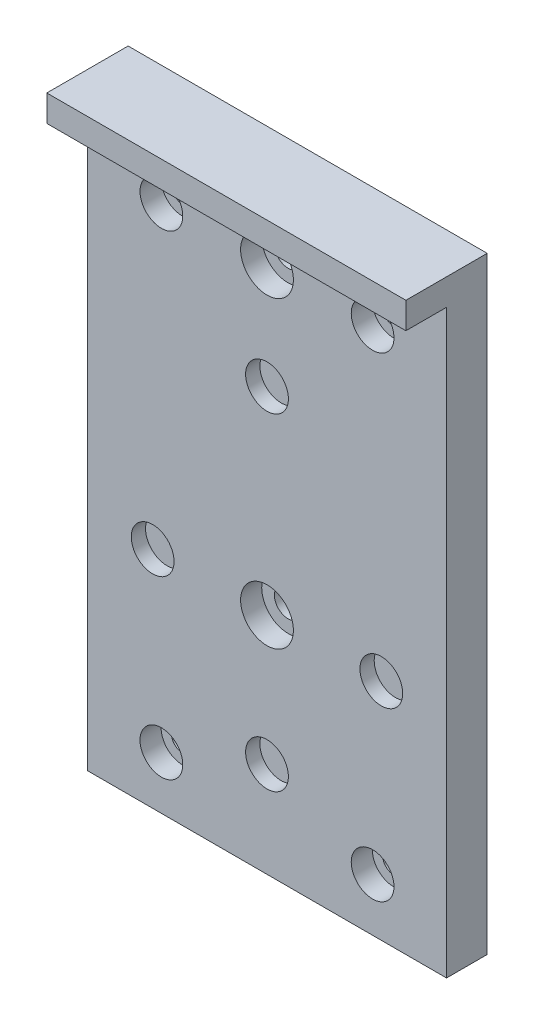
from build123d import *

# Parameters (mm, degrees)
SKETCH1_W                = 68
SKETCH1_H                = 110
SKETCH1_R                = 2.1
SKETCH1_R_2              = 4.05
SKETCH1_R_3              = 2.6
BOSS_EXTRUDE1_DEPTH      = 7.7
SKETCH2_R                = 6.304633146
SKETCH2_R_2              = 7.334333348
SKETCH2_R_3              = 8.114040952
SKETCH2_R_4              = 11.073656437
BOSS_EXTRUDE2_DEPTH      = 5
SKETCH3_R                = 4.05
SKETCH3_R_2              = 5
CUT_EXTRUDE1_DEPTH       = 4
SKETCH4_W                = 68
SKETCH4_H                = 5
BOSS_EXTRUDE3_DEPTH      = 7.7
BOSS_EXTRUDE3_DEPTH_BACK = 7.7


with BuildPart() as part:
    # Sketch1 → Boss-Extrude1 (new body)
    with BuildSketch(Plane.XY):
        Rectangle(SKETCH1_W, SKETCH1_H)
        with Locations((20, 45)):
            Circle(SKETCH1_R, mode=Mode.SUBTRACT)
        with Locations((-20, 45)):
            Circle(SKETCH1_R, mode=Mode.SUBTRACT)
        with Locations((20, -45)):
            Circle(SKETCH1_R, mode=Mode.SUBTRACT)
        with Locations((-20, -45)):
            Circle(SKETCH1_R, mode=Mode.SUBTRACT)
        with Locations((21.650635095, -12.5)):
            Circle(SKETCH1_R_2, mode=Mode.SUBTRACT)
        with Locations((0, 25)):
            Circle(SKETCH1_R_2, mode=Mode.SUBTRACT)
        with Locations((-21.650635095, -12.5)):
            Circle(SKETCH1_R_2, mode=Mode.SUBTRACT)
        with Locations((0, -36.95)):
            Circle(SKETCH1_R_2, mode=Mode.SUBTRACT)
        with Locations((0, 45)):
            Circle(SKETCH1_R_3, mode=Mode.SUBTRACT)
        with Locations((0, -12.5)):
            Circle(SKETCH1_R_3, mode=Mode.SUBTRACT)
    extrude(amount=BOSS_EXTRUDE1_DEPTH)

    # Sketch2 → Boss-Extrude2 (add)
    with BuildSketch(Plane(origin=(0, 0, 0), x_dir=(-1, 0, 0), z_dir=(0, 0, -1))):
        with Locations((-21.650635095, -12.5)):
            Circle(SKETCH2_R)
        with Locations((0, 25)):
            Circle(SKETCH2_R_2)
        with Locations((21.650635095, -12.5)):
            Circle(SKETCH2_R_3)
        with Locations((0, -36.95)):
            Circle(SKETCH2_R_4)
    extrude(amount=-BOSS_EXTRUDE2_DEPTH)

    # Sketch3 → Cut-Extrude1 (cut)
    with BuildSketch(Plane(origin=(0, 0, 7.7), x_dir=(-1, 0, 0), z_dir=(0, 0, -1))):
        with Locations((-20, 45)):
            Circle(SKETCH3_R)
        with Locations((20, 45)):
            Circle(SKETCH3_R)
        with Locations((-20, -45)):
            Circle(SKETCH3_R)
        with Locations((20, -45)):
            Circle(SKETCH3_R)
        with Locations((0, 45)):
            Circle(SKETCH3_R_2)
        with Locations((0, -12.5)):
            Circle(SKETCH3_R_2)
    extrude(amount=CUT_EXTRUDE1_DEPTH, mode=Mode.SUBTRACT)

    # Sketch4 → Boss-Extrude3 (add, two sides)
    with BuildSketch(Plane.XY.offset(7.7)) as boss_extrude3_sk:
        with Locations((0, 57.5)):
            Rectangle(SKETCH4_W, SKETCH4_H)
    extrude(amount=BOSS_EXTRUDE3_DEPTH)
    extrude(boss_extrude3_sk.sketch, amount=-BOSS_EXTRUDE3_DEPTH_BACK)


solid = part.part
